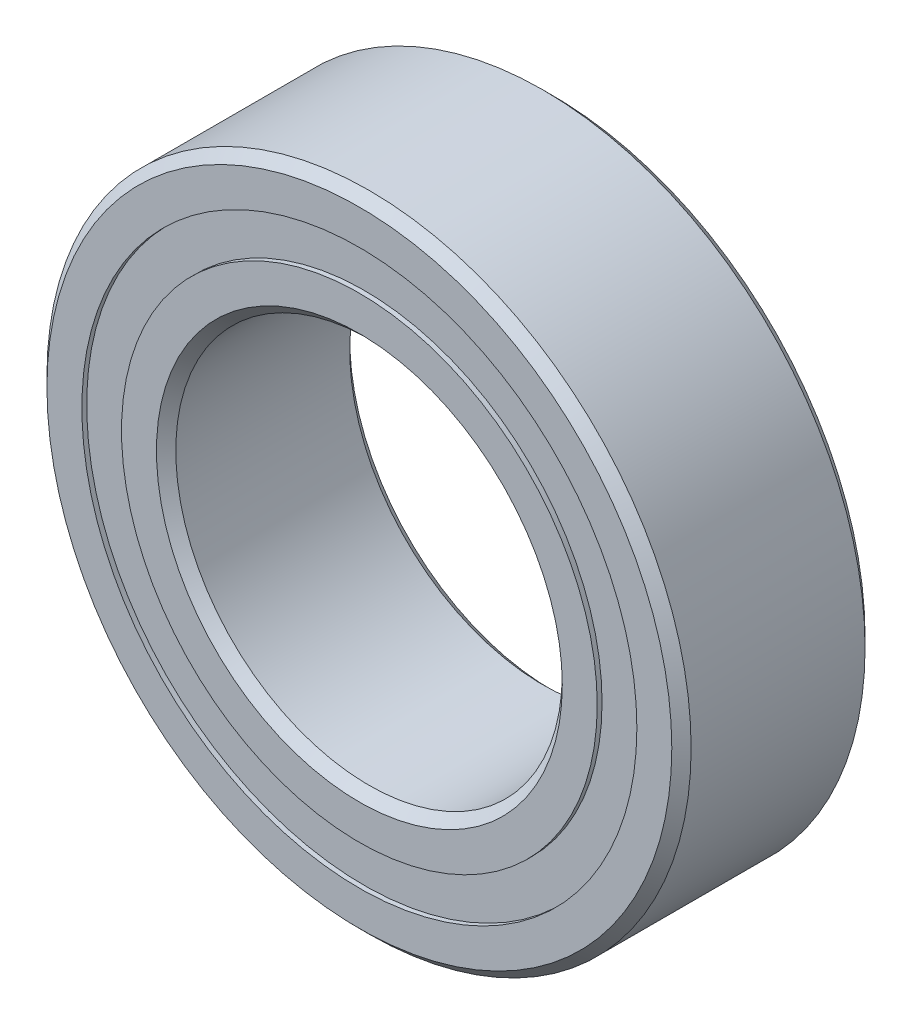
from build123d import *

# Parameters (mm, degrees)
CIRPATTERN1_COUNT = 12
SKETCH5_W         = 0.690752766
SKETCH5_H         = 0.615384616


with BuildPart() as part:
    # Sketch1 → Revolve1 (revolve)
    with BuildSketch(Plane(origin=(0, 0, 0), x_dir=(0, 0, -1), z_dir=(1, 0, 0))):
        with BuildLine():
            Line((1.35, 5), (-1.35, 5))
            Line((-1.35, 5), (-1.5, 4.85))
            Line((-1.5, 4.85), (-1.5, 4.307692308))
            Line((-1.5, 4.307692308), (-0.666666667, 4.307692308))
            ThreePointArc((-0.666666667, 4.307692308), (0, 4.734247234), (0.666666667, 4.307692308))
            Line((0.666666667, 4.307692308), (1.5, 4.307692308))
            Line((1.5, 4.307692308), (1.5, 4.85))
            Line((1.5, 4.85), (1.35, 5))
        make_face()
    revolve(axis=Axis((0, 0, 1.5), (0, 0, -1)))


with BuildPart() as body_2:
    # Sketch3 → Revolve3 (revolve)
    with BuildSketch(Plane(origin=(0, 0, 0), x_dir=(0, 0, -1), z_dir=(1, 0, 0))):
        with BuildLine():
            Line((-1.5, 3.692307692), (-0.666666667, 3.692307692))
            ThreePointArc((-0.666666667, 3.692307692), (0, 3.265752766), (0.666666667, 3.692307692))
            Line((0.666666667, 3.692307692), (1.5, 3.692307692))
            Line((1.5, 3.692307692), (1.5, 3.15))
            Line((1.5, 3.15), (1.35, 3))
            Line((1.35, 3), (-1.35, 3))
            Line((-1.35, 3), (-1.5, 3.15))
            Line((-1.5, 3.15), (-1.5, 3.692307692))
        make_face()
    revolve(axis=Axis((0, 0, 1.5), (0, 0, -1)))


with BuildPart() as body_3:
    # Sketch4 → Revolve4 (revolve)
    with BuildSketch(Plane(origin=(0, 0, 0), x_dir=(0, 0, -1), z_dir=(1, 0, 0))):
        with BuildLine():
            Line((-0.734247234, 4), (0.734247234, 4))
            ThreePointArc((0.734247234, 4), (0, 4.734247234), (-0.734247234, 4))
        make_face()
    revolve(axis=Axis((0, 4, 0.734247234), (0, 0, -1)))


with BuildPart() as cirpattern1_1:
    # CirPattern1: pattern copy
    add(body_3.part.rotate(Axis((0, 0, -1.5), (0, 0, 1)), 1 * 360 / CIRPATTERN1_COUNT))


with BuildPart() as cirpattern1_2:
    # CirPattern1: pattern copy
    add(body_3.part.rotate(Axis((0, 0, -1.5), (0, 0, 1)), 2 * 360 / CIRPATTERN1_COUNT))


with BuildPart() as cirpattern1_3:
    # CirPattern1: pattern copy
    add(body_3.part.rotate(Axis((0, 0, -1.5), (0, 0, 1)), 3 * 360 / CIRPATTERN1_COUNT))


with BuildPart() as cirpattern1_4:
    # CirPattern1: pattern copy
    add(body_3.part.rotate(Axis((0, 0, -1.5), (0, 0, 1)), 4 * 360 / CIRPATTERN1_COUNT))


with BuildPart() as cirpattern1_5:
    # CirPattern1: pattern copy
    add(body_3.part.rotate(Axis((0, 0, -1.5), (0, 0, 1)), 5 * 360 / CIRPATTERN1_COUNT))


with BuildPart() as cirpattern1_6:
    # CirPattern1: pattern copy
    add(body_3.part.rotate(Axis((0, 0, -1.5), (0, 0, 1)), 6 * 360 / CIRPATTERN1_COUNT))


with BuildPart() as cirpattern1_7:
    # CirPattern1: pattern copy
    add(body_3.part.rotate(Axis((0, 0, -1.5), (0, 0, 1)), 7 * 360 / CIRPATTERN1_COUNT))


with BuildPart() as cirpattern1_8:
    # CirPattern1: pattern copy
    add(body_3.part.rotate(Axis((0, 0, -1.5), (0, 0, 1)), 8 * 360 / CIRPATTERN1_COUNT))


with BuildPart() as cirpattern1_9:
    # CirPattern1: pattern copy
    add(body_3.part.rotate(Axis((0, 0, -1.5), (0, 0, 1)), 9 * 360 / CIRPATTERN1_COUNT))


with BuildPart() as cirpattern1_10:
    # CirPattern1: pattern copy
    add(body_3.part.rotate(Axis((0, 0, -1.5), (0, 0, 1)), 10 * 360 / CIRPATTERN1_COUNT))


with BuildPart() as cirpattern1_11:
    # CirPattern1: pattern copy
    add(body_3.part.rotate(Axis((0, 0, -1.5), (0, 0, 1)), 11 * 360 / CIRPATTERN1_COUNT))


with BuildPart() as body_15:
    # Sketch5 → Revolve5 (revolve)
    with BuildSketch(Plane(origin=(0, 0, 0), x_dir=(0, 0, -1), z_dir=(1, 0, 0))):
        with Locations((-1.079623617, 4)):
            Rectangle(SKETCH5_W, SKETCH5_H)
        with Locations((1.079623617, 4)):
            Rectangle(SKETCH5_W, SKETCH5_H)
    revolve(axis=Axis((0, 0, 1.5), (0, 0, -1)))


solid = Compound([part.part, body_2.part, body_3.part, cirpattern1_1.part, cirpattern1_2.part, cirpattern1_3.part, cirpattern1_4.part, cirpattern1_5.part, cirpattern1_6.part, cirpattern1_7.part, cirpattern1_8.part, cirpattern1_9.part, cirpattern1_10.part, cirpattern1_11.part, body_15.part])
